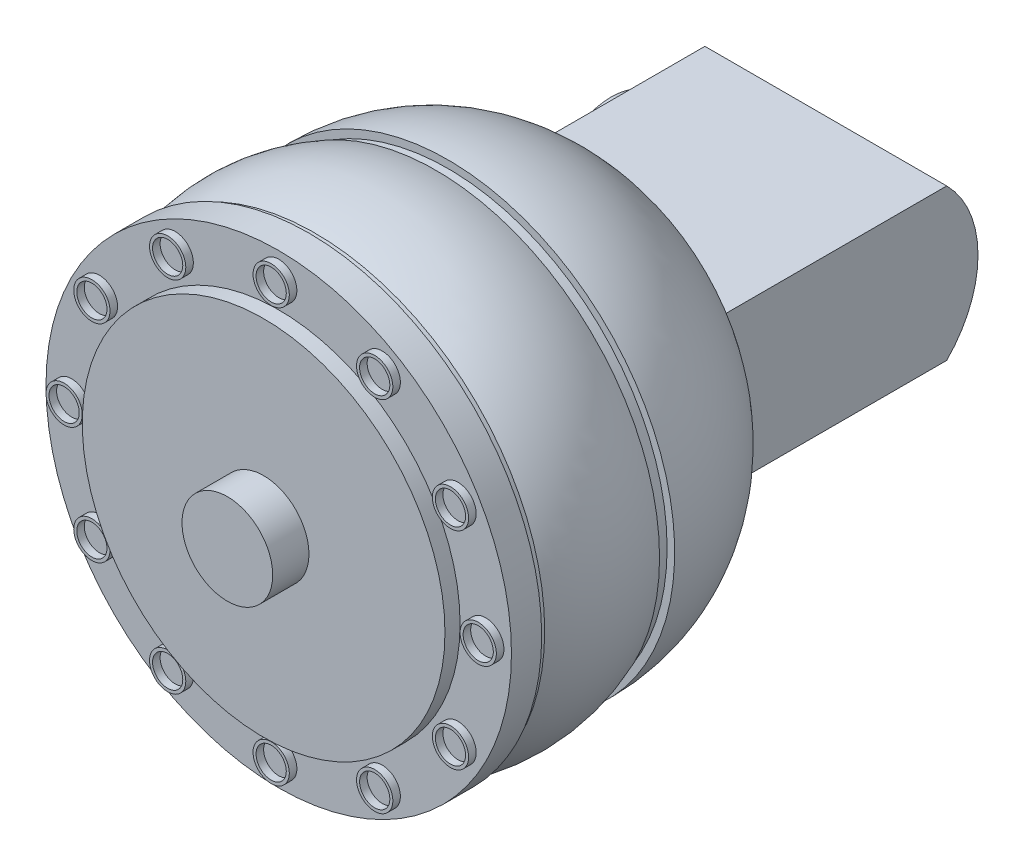
from build123d import *

# Parameters (mm, degrees)
SKETCH3_R           = 18.415
BOSS_EXTRUDE1_DEPTH = 1.016
SKETCH5_R           = 19.304
BOSS_EXTRUDE2_DEPTH = 0.508
SKETCH6_R           = 19.558
BOSS_EXTRUDE3_DEPTH = 2.54
SKETCH7_R           = 15.24
BOSS_EXTRUDE4_DEPTH = 1.27
SKETCH8_R           = 1.524
SKETCH8_R_2         = 1.27
BOSS_EXTRUDE5_DEPTH = 0.635
CIRPATTERN1_COUNT   = 12
SKETCH9_W           = 20.32
SKETCH9_H           = 12.7
BOSS_EXTRUDE6_DEPTH = 19.05
BOSS_EXTRUDE7_DEPTH = 20.32
SKETCH12_R          = 3.81
BOSS_EXTRUDE8_DEPTH = 3.048
SKETCH13_R          = 5.08
BOSS_EXTRUDE9_DEPTH = 1.524


with BuildPart() as part:
    # Sketch1 → Revolve3 (revolve)
    with BuildSketch(Plane(origin=(0, 0, 0), x_dir=(1, 0, 0), z_dir=(0, 1, 0))):
        with BuildLine():
            Line((0, 0), (0, -12.7))
            Line((0, -12.7), (-19.05, -12.7))
            ThreePointArc((-19.05, -12.7), (-17.408709569, -5.583145216), (-12.7, 0))
            Line((-12.7, 0), (0, 0))
        make_face()
    revolve(axis=Axis((0, 0, 0), (0, 0, 1)))

    # Sketch3 → Boss-Extrude1 (add)
    with BuildSketch(Plane.XY.offset(12.7)):
        Circle(SKETCH3_R)
    extrude(amount=BOSS_EXTRUDE1_DEPTH)

    # Sketch4 → Revolve4 (revolve)
    with BuildSketch(Plane(origin=(0, 0, 0), x_dir=(1, 0, 0), z_dir=(0, 1, 0))):
        with BuildLine():
            Line((0, -13.716), (-18.796, -13.716))
            ThreePointArc((-18.796, -13.716), (-19.781066859, -18.796), (-18.796, -23.876))
            Line((-18.796, -23.876), (0, -23.876))
            Line((0, -23.876), (0, -13.716))
        make_face()
    revolve(axis=Axis((0, 0, 23.876), (0, 0, -1)))

    # Sketch5 → Boss-Extrude2 (add)
    with BuildSketch(Plane.XY.offset(23.876)):
        Circle(SKETCH5_R)
    extrude(amount=BOSS_EXTRUDE2_DEPTH)

    # Sketch6 → Boss-Extrude3 (add)
    with BuildSketch(Plane.XY.offset(24.384)):
        Circle(SKETCH6_R)
    extrude(amount=BOSS_EXTRUDE3_DEPTH)

    # Sketch7 → Boss-Extrude4 (add)
    with BuildSketch(Plane.XY.offset(26.924)):
        Circle(SKETCH7_R)
    extrude(amount=BOSS_EXTRUDE4_DEPTH)

    # Sketch8 → Boss-Extrude5 (add)
    with BuildSketch(Plane.XY.offset(26.924)):
        with Locations((17.399, 0)):
            Circle(SKETCH8_R)
        with Locations((17.399, 0)):
            Circle(SKETCH8_R_2, mode=Mode.SUBTRACT)
    boss_extrude5 = extrude(amount=BOSS_EXTRUDE5_DEPTH)

    # CirPattern1: Boss-Extrude5 ×12 about axis
    cirpattern1_axis = Axis((0, 0, 0), (0, 0, 1))
    for i in range(1, CIRPATTERN1_COUNT):
        add(boss_extrude5.rotate(cirpattern1_axis, i * 360 / CIRPATTERN1_COUNT))

    # Sketch9 → Boss-Extrude6 (add)
    with BuildSketch(Plane(origin=(0, 0, 0), x_dir=(-1, 0, 0), z_dir=(0, 0, -1))):
        Rectangle(SKETCH9_W, SKETCH9_H)
    extrude(amount=BOSS_EXTRUDE6_DEPTH)

    # Sketch10 → Boss-Extrude7 (add)
    with BuildSketch(Plane(origin=(10.16, 0, 0), x_dir=(0, 0, -1), z_dir=(1, 0, 0))):
        with BuildLine():
            Line((19.05, 6.35), (19.05, -6.35))
            ThreePointArc((19.05, -6.35), (21.680256121, 0), (19.05, 6.35))
        make_face()
    extrude(amount=-BOSS_EXTRUDE7_DEPTH)

    # Sketch12 → Boss-Extrude8 (add)
    with BuildSketch(Plane.XY.offset(28.194)):
        Circle(SKETCH12_R)
    extrude(amount=BOSS_EXTRUDE8_DEPTH)

    # Sketch13 → Boss-Extrude9 (add)
    with BuildSketch(Plane.ZY.offset(10.16)):
        with Locations((-12.7, 0)):
            Circle(SKETCH13_R)
    extrude(amount=BOSS_EXTRUDE9_DEPTH)


solid = part.part
